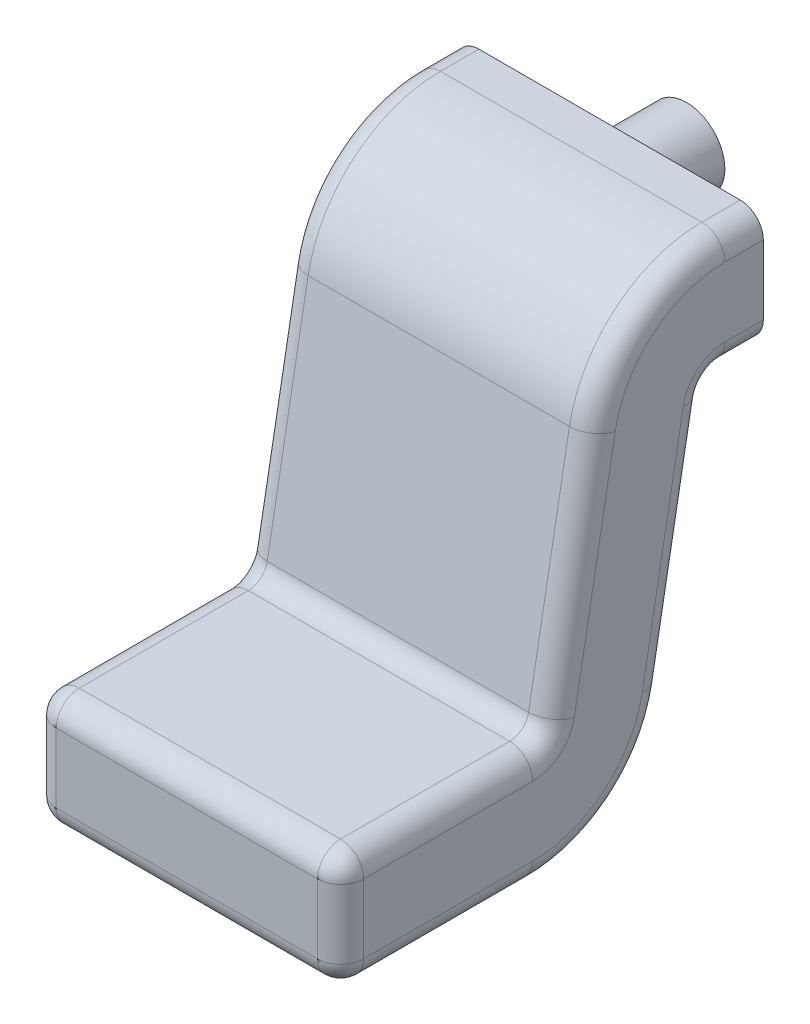
from build123d import *

# Parameters (mm, degrees)
FILETE2_R                = 0.03
ESBO_O3_R                = 0.05
RESSALTO_EXTRUS_O1_DEPTH = 0.1


with BuildPart() as part:
    # Varredura1: sweep along a path in Esboço2
    with BuildLine(Plane(origin=(0, 0, 0), x_dir=(0, 0, -1), z_dir=(1, 0, 0))) as varredura1_path:
        Line((0, 0), (0.25, 0))
        ThreePointArc((0.25, 0), (0.314144085, 0.023282751), (0.348419155, 0.082289274))
        Line((0.348419155, 0.082289274), (0.401580845, 0.377710726))
        ThreePointArc((0.401580845, 0.377710726), (0.435855915, 0.436717249), (0.5, 0.46))
        Line((0.5, 0.46), (0.55, 0.46))
    # Esboço1 → Varredura1 (sweep)
    with BuildSketch(Plane.XY):
        with BuildLine():
            Line((-0.17, -0.075), (0.17, -0.075))
            ThreePointArc((0.17, -0.075), (0.191213203, -0.066213203), (0.2, -0.045))
            Line((0.2, -0.045), (0.2, 0.045))
            ThreePointArc((0.2, 0.045), (0.191213203, 0.066213203), (0.17, 0.075))
            Line((0.17, 0.075), (-0.17, 0.075))
            ThreePointArc((-0.17, 0.075), (-0.191213203, 0.066213203), (-0.2, 0.045))
            Line((-0.2, 0.045), (-0.2, -0.045))
            ThreePointArc((-0.2, -0.045), (-0.191213203, -0.066213203), (-0.17, -0.075))
        make_face()
    sweep(path=varredura1_path.line)

    # Filete2
    filete2_edges = [part.edges().sort_by_distance(p)[0] for p in [
        (-0.2, 0, 0),
        (-0.191213203, 0.066213203, 0),
        (0, 0.075, 0),
        (0.191213203, 0.066213203, 0),
        (0.2, 0, 0),
        (0.191213203, -0.066213203, 0),
        (0, -0.075, 0),
        (-0.191213203, -0.066213203, 0),
    ]]
    fillet(filete2_edges, radius=FILETE2_R)

    # Esboço3 → Ressalto-extrusão1 (add)
    with BuildSketch(Plane(origin=(0, 0, -0.55), x_dir=(-1, 0, 0), z_dir=(0, 0, -1))):
        with Locations((0, 0.46)):
            Circle(ESBO_O3_R)
    extrude(amount=RESSALTO_EXTRUS_O1_DEPTH)


solid = part.part
